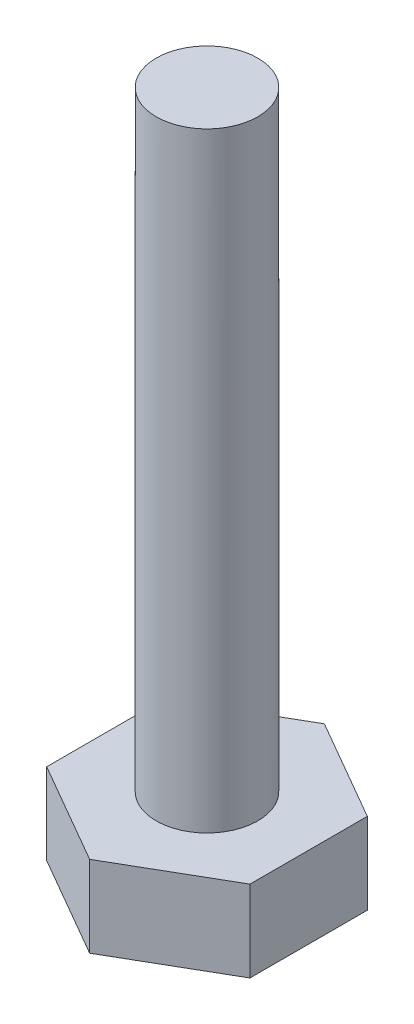
from build123d import *

# Parameters (mm, degrees)
SKETCH1_R           = 2.5
BOSS_EXTRUDE1_DEPTH = 30
BOSS_EXTRUDE2_DEPTH = 4


with BuildPart() as part:
    # Sketch1 → Boss-Extrude1 (new body)
    with BuildSketch(Plane(origin=(0, 0, 0), x_dir=(1, 0, 0), z_dir=(0, 1, 0))):
        Circle(SKETCH1_R)
    extrude(amount=BOSS_EXTRUDE1_DEPTH)

    # Sketch2 → Boss-Extrude2 (add)
    with BuildSketch(Plane.XZ):
        Polygon((0, 5.773502692), (-5, 2.886751346), (-5, -2.886751346), (0, -5.773502692), (5, -2.886751346), (5, 2.886751346), align=None)
    extrude(amount=BOSS_EXTRUDE2_DEPTH)


solid = part.part
